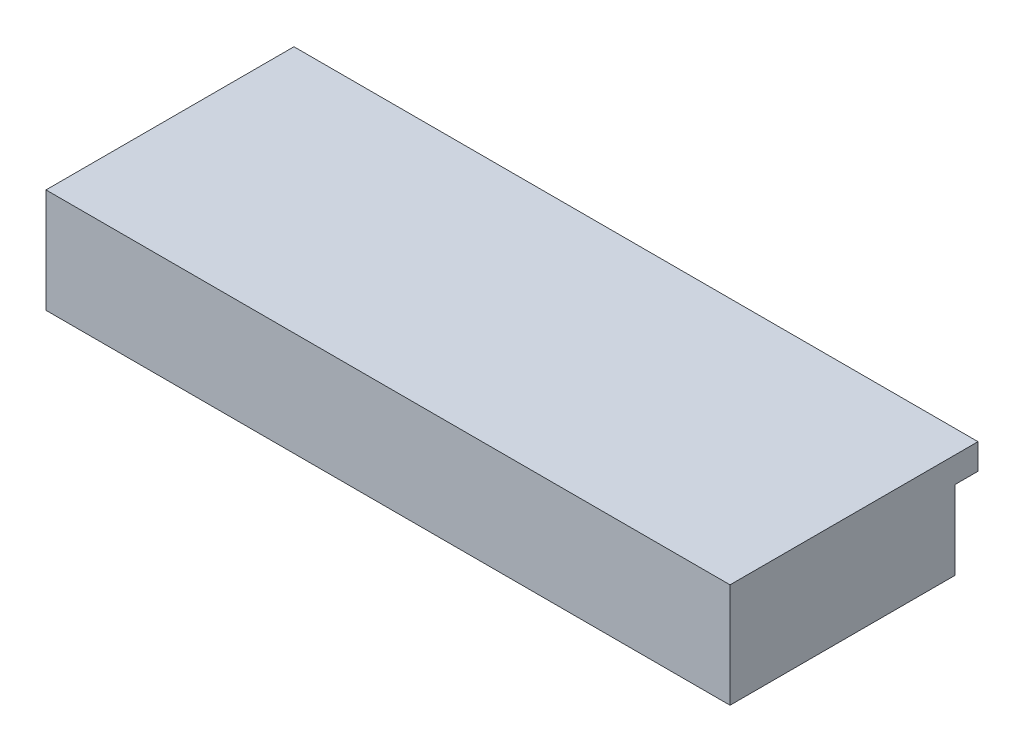
from build123d import *

# Parameters (mm, degrees)
EXTRUSION1_DEPTH = 1.5
ESQUISSE3_W      = 400
ESQUISSE3_H      = 46
EXTRUSION2_DEPTH = 130
ESQUISSE4_W      = 400
ESQUISSE4_H      = 15
EXTRUSION3_DEPTH = 145


with BuildPart() as part:
    # Esquisse2 → Extrusion1 (new body)
    with BuildSketch(Plane.XY):
        with BuildLine():
            Line((238, -21), (70.5, -21))
            Line((70.5, -21), (70.5, -8))
            ThreePointArc((70.5, -8), (71.085786438, -6.585786438), (72.5, -6))
            Line((72.5, -6), (83, -6))
            ThreePointArc((83, -6), (95.5, 6.5), (83, 19))
            Line((83, 19), (-70.25, 19))
            ThreePointArc((-70.25, 19), (-82.75, 6.5), (-70.25, -6))
            Line((-70.25, -6), (-61.5, -6))
            ThreePointArc((-61.5, -6), (-60.085786438, -6.585786438), (-59.5, -8))
            Line((-59.5, -8), (-59.5, -21))
            Line((-59.5, -21), (-162, -21))
            Line((-162, -21), (-162, 25))
            Line((-162, 25), (238, 25))
            Line((238, 25), (238, -21))
        make_face()
    extrude(amount=-EXTRUSION1_DEPTH)

    # Esquisse3 → Extrusion2 (add)
    with BuildSketch(Plane.XY):
        with Locations((38, 2)):
            Rectangle(ESQUISSE3_W, ESQUISSE3_H)
    extrude(amount=EXTRUSION2_DEPTH)

    # Esquisse4 → Extrusion3 (add)
    with BuildSketch(Plane.XY.offset(130)):
        with Locations((38, 32.5)):
            Rectangle(ESQUISSE4_W, ESQUISSE4_H)
    extrude(amount=-EXTRUSION3_DEPTH)


solid = part.part
